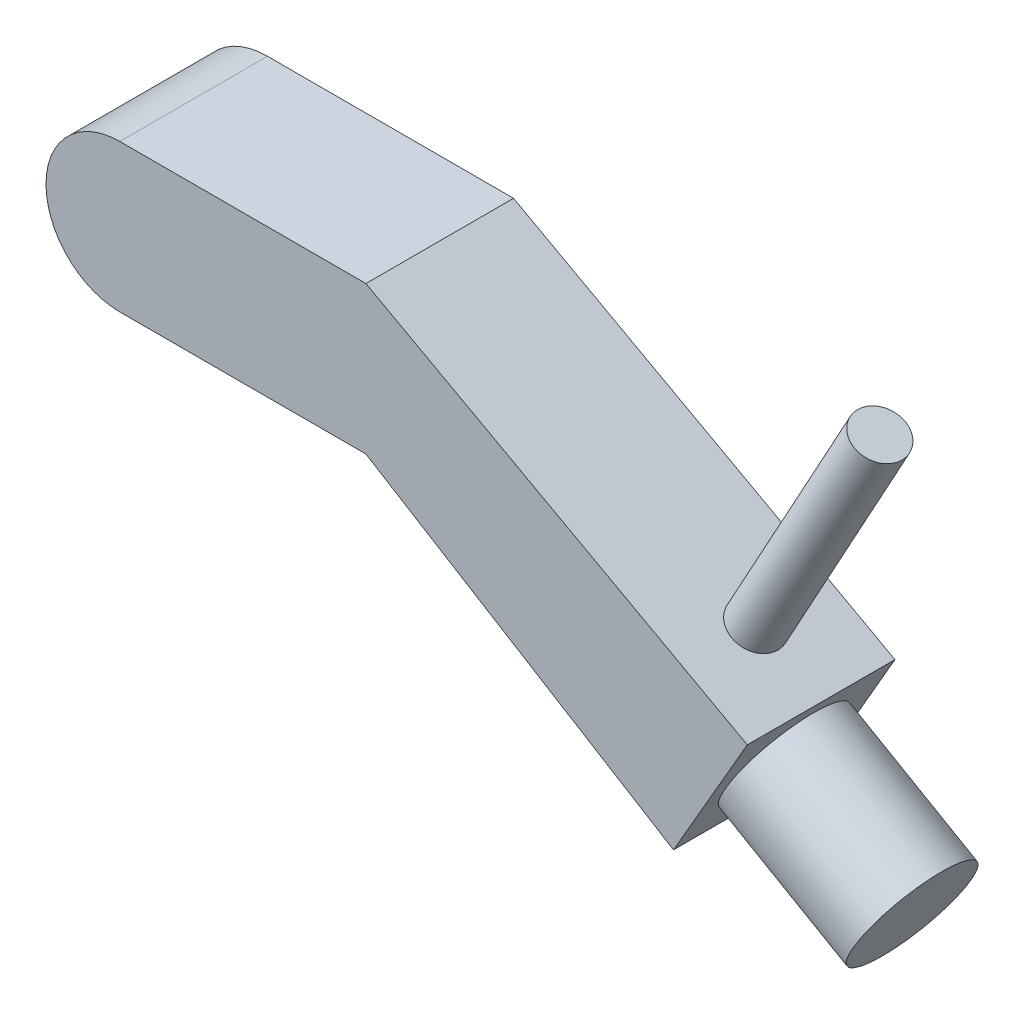
from build123d import *

# Parameters (mm, degrees)
BOSS_EXTRUDE1_DEPTH = 15
SKETCH4_R           = 12
BOSS_EXTRUDE2_DEPTH = 30
BOSS_EXTRUDE3_REACH = 169.037
SKETCH5_R           = 5


with BuildPart() as part:
    # Sketch1 → Boss-Extrude1 (new, symmetric)
    with BuildSketch(Plane.XY):
        with BuildLine():
            Line((127.5, -27.424137787), (112.5, -53.4048999))
            Line((112.5, -53.4048999), (50, -15))
            Line((50, -15), (0, -15))
            ThreePointArc((0, -15), (-15, 0), (0, 15))
            Line((0, 15), (50, 15))
            Line((50, 15), (127.5, -27.424137787))
        make_face()
    extrude(amount=BOSS_EXTRUDE1_DEPTH, both=True)

    # Sketch4 → Boss-Extrude2 (add)
    with BuildSketch(Plane(origin=(107.5, -62.065153938, 0), x_dir=(0, 0, -1), z_dir=(0.8660254037844382, -0.5000000000000008, 0))):
        with Locations(Location((0, 25, 0), (0, 0, 270))):
            Circle(SKETCH4_R)
    extrude(amount=BOSS_EXTRUDE2_DEPTH)

    # Boss-Extrude3: up to this plane
    boss_extrude3_end = Plane(origin=(122.500102159, 33.814123489, 15), z_dir=(-0.43702455737153567, -0.8994495740474913, 0))
    # Sketch5 → Boss-Extrude3 (add, up to the surface)
    with BuildSketch(Plane(origin=(17.846196254, 32.601256781, 0), x_dir=(0.877174161572964, -0.48017235475271564, 0), z_dir=(0.4801723547527156, 0.8771741615729639, 0)), mode=Mode.PRIVATE) as boss_extrude3_sk1:
        with Locations((110.008018419, 0)):
            Circle(SKETCH5_R)
    boss_extrude3_tool1 = split(extrude(boss_extrude3_sk1.sketch, amount=BOSS_EXTRUDE3_REACH, mode=Mode.PRIVATE), bisect_by=boss_extrude3_end, keep=Keep.BOTH, mode=Mode.PRIVATE)
    add(boss_extrude3_tool1.solids().sort_by_distance((114.342388, -20.221552, 0))[0])


solid = part.part
